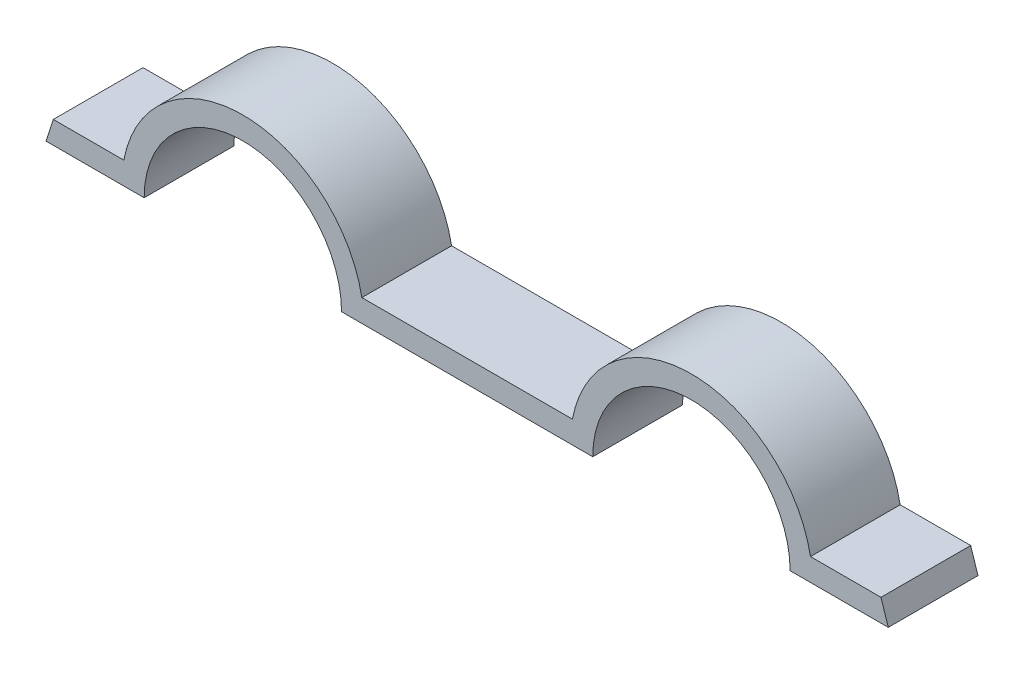
from build123d import *

# Parameters (mm, degrees)
BOSS_EXTRUDE2_DEPTH = 6.35


with BuildPart() as part:
    # Sketch1 → Boss-Extrude2 (new body)
    with BuildSketch(Plane.XY):
        with BuildLine():
            Line((-29.806543337, 171.972726708), (-22.86, 171.972726708))
            ThreePointArc((-22.86, 171.972726708), (-15.875, 178.957726708), (-8.89, 171.972726708))
            Line((-8.89, 171.972726708), (8.89, 171.972726708))
            ThreePointArc((8.89, 171.972726708), (15.875, 178.957726708), (22.86, 171.972726708))
            Line((22.86, 171.972726708), (29.806543337, 171.972726708))
            Line((29.806543337, 171.972726708), (29.290036257, 173.560226708))
            Line((29.290036257, 173.560226708), (24.299226968, 173.560226708))
            ThreePointArc((24.299226968, 173.560226708), (15.875, 180.545226708), (7.450773032, 173.560226708))
            Line((7.450773032, 173.560226708), (-7.450773032, 173.560226708))
            ThreePointArc((-7.450773032, 173.560226708), (-15.875, 180.545226708), (-24.299226968, 173.560226708))
            Line((-24.299226968, 173.560226708), (-29.290036257, 173.560226708))
            Line((-29.290036257, 173.560226708), (-29.806543337, 171.972726708))
        make_face()
    extrude(amount=BOSS_EXTRUDE2_DEPTH)


solid = part.part
